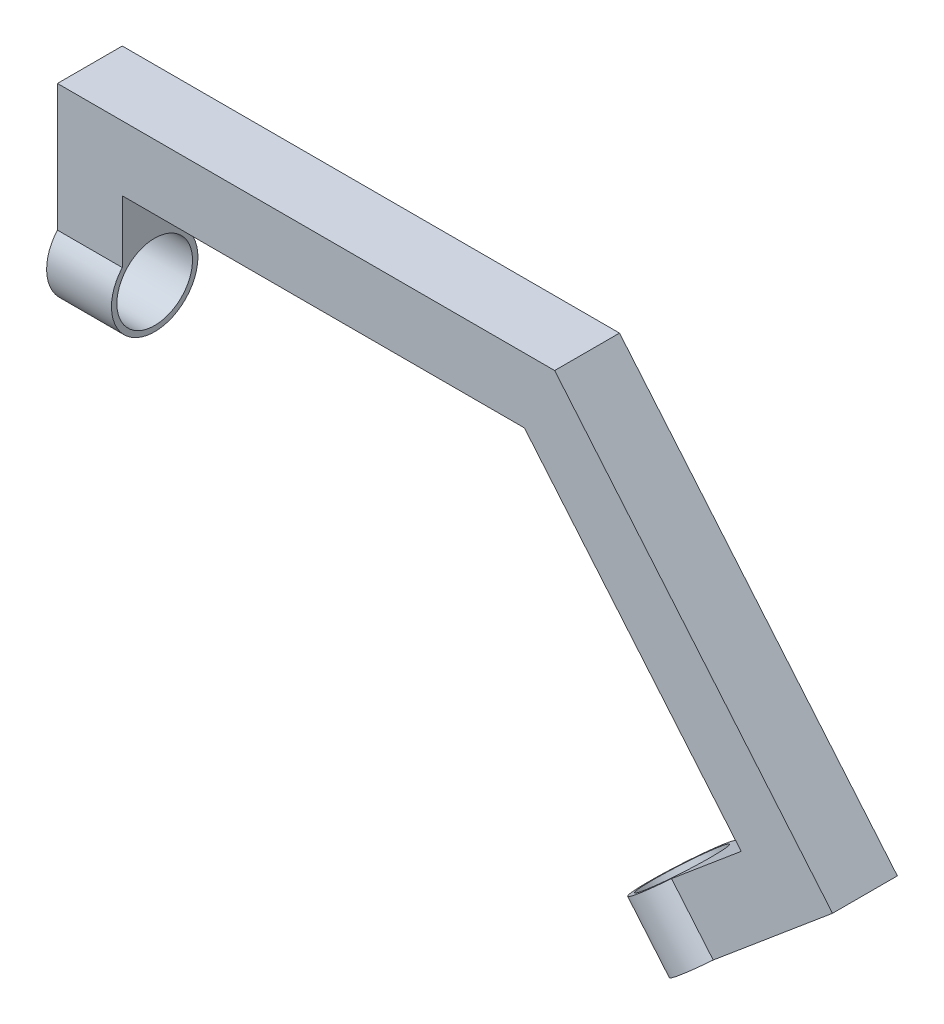
from build123d import *

# Parameters (mm, degrees)
BOSS_EXTRUDE1_DEPTH      = 9.525
BOSS_EXTRUDE1_DEPTH_BACK = 9.525
SKETCH2_R                = 12.7
BOSS_EXTRUDE2_DEPTH      = 19.05
SKETCH3_R                = 12.7
BOSS_EXTRUDE3_DEPTH      = 19.05
SKETCH4_R                = 11.1125
CUT_EXTRUDE1_DEPTH       = 19.05
SKETCH5_R                = 11.1125
CUT_EXTRUDE2_DEPTH       = 19.05


with BuildPart() as part:
    # Sketch1 → Boss-Extrude1 (new, two sides: drawn at the far end of the back side and taken through both)
    with BuildSketch(Plane.XY.offset(-BOSS_EXTRUDE1_DEPTH_BACK)):
        Polygon((14.619756732, 5.945361145), (41.514078034, 28.51237623), (-22.164858678, 104.401977829), (-140.313745495, 104.401977829), (-140.313745495, 77.731977829), (-159.363745495, 77.731977829), (-159.363745495, 123.451977829), (-13.281697791, 123.451977829), (68.35232864, 26.164333553), (26.864860696, -8.647785497), align=None)
    extrude(amount=BOSS_EXTRUDE1_DEPTH + BOSS_EXTRUDE1_DEPTH_BACK)

    # Sketch2 → Boss-Extrude2 (add)
    with BuildSketch(Plane.ZY.offset(159.363745495)):
        with Locations((0, 77.731977829)):
            Circle(SKETCH2_R)
    extrude(amount=-BOSS_EXTRUDE2_DEPTH)

    # Sketch3 → Boss-Extrude3 (add)
    with BuildSketch(Plane(origin=(15.358116398, -18.303090393, 0), x_dir=(0.7660444431189792, 0.6427876096865379, 0), z_dir=(0.6427876096865379, -0.7660444431189792, 0))):
        with Locations((15.020987883, 0)):
            Circle(SKETCH3_R)
    extrude(amount=-BOSS_EXTRUDE3_DEPTH)

    # Sketch4 → Cut-Extrude1 (cut)
    with BuildSketch(Plane(origin=(15.358116398, -18.303090393, 0), x_dir=(0.7660444431189792, 0.6427876096865379, 0), z_dir=(0.6427876096865379, -0.7660444431189792, 0))):
        with Locations((15.020987883, 0)):
            Circle(SKETCH4_R)
    extrude(amount=-CUT_EXTRUDE1_DEPTH, mode=Mode.SUBTRACT)

    # Sketch5 → Cut-Extrude2 (cut)
    with BuildSketch(Plane.ZY.offset(159.363745495)):
        with Locations((0, 77.731977829)):
            Circle(SKETCH5_R)
    extrude(amount=-CUT_EXTRUDE2_DEPTH, mode=Mode.SUBTRACT)


solid = part.part
